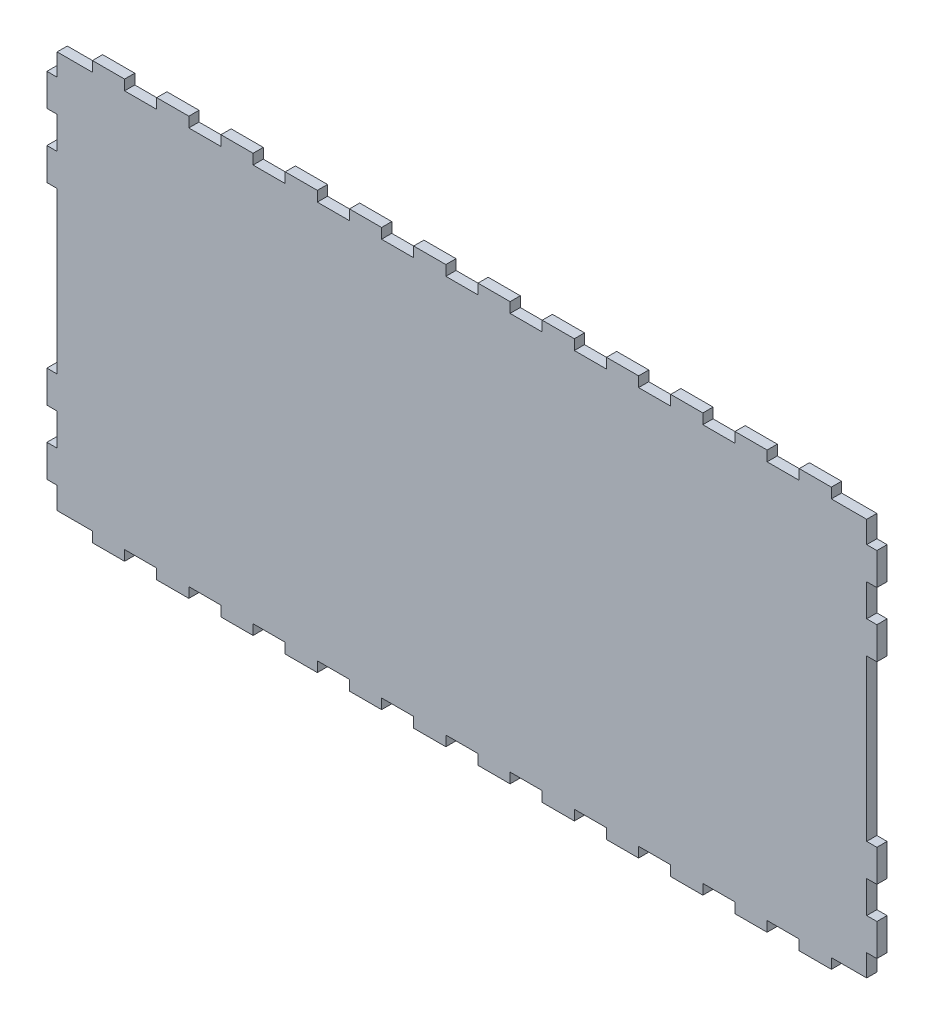
from build123d import *

# Parameters (mm, degrees)
BOSS_EXTRUDE1_DEPTH = 3.175


with BuildPart() as part:
    # Sketch1 → Boss-Extrude1 (new body)
    with BuildSketch(Plane.XY):
        Polygon((31, 123.65), (31, 126.825), (41, 126.825), (41, 123.65), (51, 123.65), (51, 126.825), (61, 126.825), (61, 123.65), (71, 123.65), (71, 126.825), (81, 126.825), (81, 123.65), (91, 123.65), (91, 126.825), (101, 126.825), (101, 123.65), (111, 123.65), (111, 126.825), (121, 126.825), (121, 123.65), (131, 123.65), (131, 126.825), (141, 126.825), (141, 123.65), (151, 123.65), (151, 126.825), (161, 126.825), (161, 123.65), (171, 123.65), (171, 126.825), (181, 126.825), (181, 123.65), (191, 123.65), (191, 126.825), (201, 126.825), (201, 123.65), (211, 123.65), (211, 126.825), (221, 126.825), (221, 123.65), (231, 123.65), (231, 126.825), (241, 126.825), (241, 123.65), (252, 123.65), (252, 116.825), (255.175, 116.825), (255.175, 106.825), (252, 106.825), (252, 96.825), (255.175, 96.825), (255.175, 86.825), (252, 86.825), (252, 36.825), (255.175, 36.825), (255.175, 26.825), (252, 26.825), (252, 16.825), (255.175, 16.825), (255.175, 6.825), (252, 6.825), (252, 0), (241, 0), (241, -3.175), (231, -3.175), (231, 0), (221, 0), (221, -3.175), (211, -3.175), (211, 0), (201, 0), (201, -3.175), (191, -3.175), (191, 0), (181, 0), (181, -3.175), (171, -3.175), (171, 0), (161, 0), (161, -3.175), (151, -3.175), (151, 0), (141, 0), (141, -3.175), (131, -3.175), (131, 0), (121, 0), (121, -3.175), (111, -3.175), (111, 0), (101, 0), (101, -3.175), (91, -3.175), (91, 0), (81, 0), (81, -3.175), (71, -3.175), (71, 0), (61, 0), (61, -3.175), (51, -3.175), (51, 0), (41, 0), (41, -3.175), (31, -3.175), (31, 0), (21, 0), (21, -3.175), (11, -3.175), (11, 0), (0, 0), (0, 6.825), (-3.175, 6.825), (-3.175, 16.825), (0, 16.825), (0, 26.825), (-3.175, 26.825), (-3.175, 36.825), (0, 36.825), (0, 86.825), (-3.175, 86.825), (-3.175, 96.825), (0, 96.825), (0, 106.825), (-3.175, 106.825), (-3.175, 116.825), (0, 116.825), (0, 123.65), (11, 123.65), (11, 126.825), (21, 126.825), (21, 123.65), align=None)
    extrude(amount=BOSS_EXTRUDE1_DEPTH)


solid = part.part
